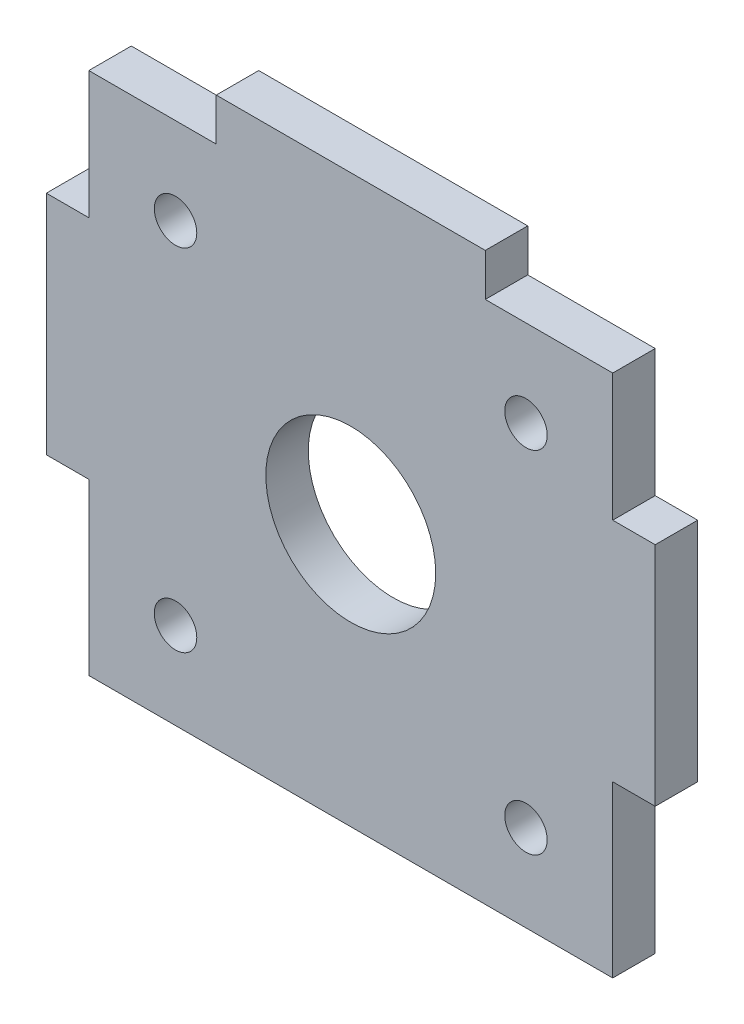
from build123d import *

# Parameters (mm, degrees)
SKETCH1_W           = 43
SKETCH1_H           = 43
SKETCH1_R           = 1.5
SKETCH1_R_2         = 6
BOSS_EXTRUDE1_DEPTH = 3
CUT_EXTRUDE1_DEPTH  = 3


with BuildPart() as part:
    # Sketch1 → Boss-Extrude1 (new body)
    with BuildSketch(Plane.XY):
        Rectangle(SKETCH1_W, SKETCH1_H)
        with Locations((-12.374368671, 12.374368671)):
            Circle(SKETCH1_R, mode=Mode.SUBTRACT)
        with Locations((12.374368671, -12.374368671)):
            Circle(SKETCH1_R, mode=Mode.SUBTRACT)
        with Locations((12.374368671, 12.374368671)):
            Circle(SKETCH1_R, mode=Mode.SUBTRACT)
        with Locations((-12.374368671, -12.374368671)):
            Circle(SKETCH1_R, mode=Mode.SUBTRACT)
        Circle(SKETCH1_R_2, mode=Mode.SUBTRACT)
    extrude(amount=BOSS_EXTRUDE1_DEPTH)

    # Sketch2 → Cut-Extrude1 (cut)
    with BuildSketch(Plane.XY.offset(3)):
        Polygon((-21.5, -21.5), (21.5, -21.5), (21.5, -18.5), (21.5, -6.5), (18.5, -6.5), (18.5, -18.5), (-18.5, -18.5), (-18.5, -6.5), (-21.5, -6.5), (-21.5, -18.5), align=None)
        Polygon((-21.5, 9.5), (-18.5, 9.5), (-18.5, 18.5), (-9.5, 18.5), (-9.5, 21.5), (-21.5, 21.5), align=None)
        Polygon((21.5, 9.5), (21.5, 21.5), (9.5, 21.5), (9.5, 18.5), (18.5, 18.5), (18.5, 9.5), align=None)
    extrude(amount=-CUT_EXTRUDE1_DEPTH, mode=Mode.SUBTRACT)


solid = part.part
